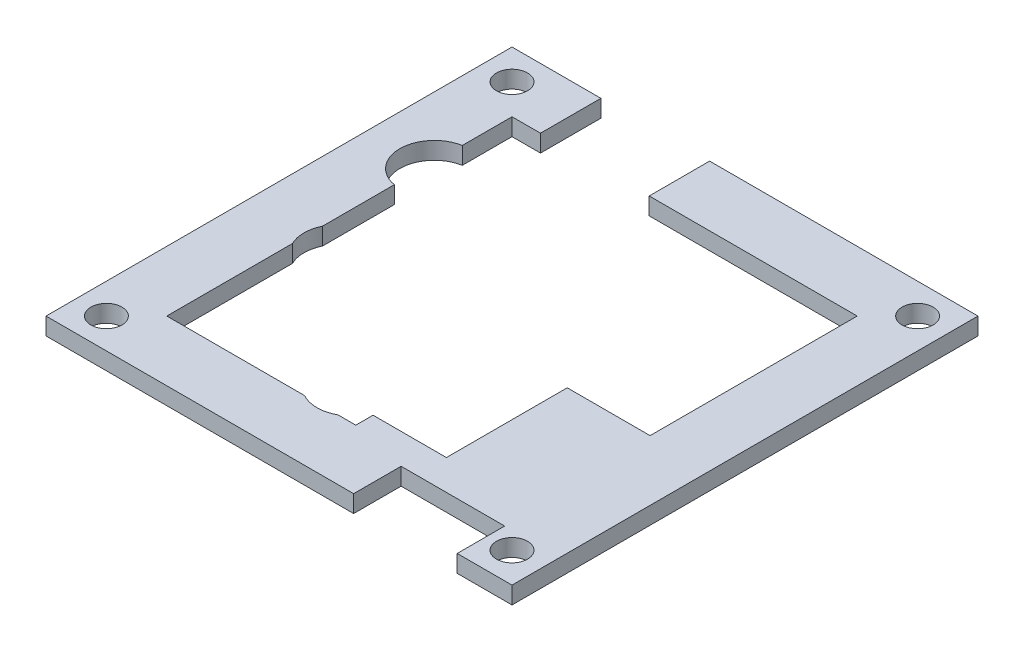
from build123d import *

# Parameters (mm, degrees)
SKETCH_3_R      = 1.8
SKETCH_3_W      = 0.8
SKETCH_3_H      = 1.5
SKETCH_3_W_2    = 1
EXTRUDE_2_DEPTH = 2


with BuildPart() as part:
    # 草图3 → 凸台-拉伸2 (new body)
    with BuildSketch(Plane(origin=(0, 0, 0), x_dir=(1, 0, 0), z_dir=(0, 1, 0))):
        with BuildLine():
            Line((8.65, -27), (8.65, -21.5))
            Line((8.65, -21.5), (8.65, -20))
            Line((8.65, -20), (1.9, -20))
            Line((1.9, -20), (-0.163508327, -20))
            ThreePointArc((-0.163508327, -20), (-2.1, -20.5), (-4.036491673, -20))
            Line((-4.036491673, -20), (-20, -20))
            Line((-20, -20), (-20, -5.443559577))
            ThreePointArc((-20, -5.443559577), (-20.4, -3.7), (-20, -1.956440423))
            Line((-20, -1.956440423), (-20, 6.361726266))
            ThreePointArc((-20, 6.361726266), (-23.3, 10.3), (-20, 14.238273734))
            Line((-20, 14.238273734), (-20, 20))
            Line((-20, 20), (-16.7, 20))
            Line((-16.7, 20), (-16.7, 27))
            Line((-16.7, 27), (-27, 27))
            Line((-27, 27), (-27, -27))
            Line((-27, -27), (8.65, -27))
        make_face()
        with Locations((-23.5, -23.5)):
            Circle(SKETCH_3_R, mode=Mode.SUBTRACT)
        with Locations((-23.5, 23.5)):
            Circle(SKETCH_3_R, mode=Mode.SUBTRACT)
        Polygon((20, -18), (20, -20), (20.65, -20), (20.65, -21.5), (20.65, -27), (27, -27), (27, 27), (-4.1, 27), (-4.1, 20), (20, 20), (20, -4), align=None)
        with Locations((23.5, -23.5)):
            Circle(SKETCH_3_R, mode=Mode.SUBTRACT)
        with Locations((23.5, 23.5)):
            Circle(SKETCH_3_R, mode=Mode.SUBTRACT)
        Polygon((12.4, -20), (12.4, -19.5), (12.4, -18), (10.4, -18), (1.9, -18), (1.9, -20), (8.65, -20), align=None)
        Polygon((20, -20), (16.9, -20), (16.9, -19.5), (16.1, -19.5), (13.4, -19.5), (12.4, -19.5), (12.4, -20), (8.65, -20), (8.65, -21.5), (20.65, -21.5), (20.65, -20), align=None)
        Polygon((16.9, -19.5), (16.9, -20), (20, -20), (20, -18), (16.9, -18), align=None)
        with Locations((16.5, -18.75)):
            Rectangle(SKETCH_3_W, SKETCH_3_H)
        with Locations((12.9, -18.75)):
            Rectangle(SKETCH_3_W_2, SKETCH_3_H)
        Polygon((16.1, -18), (16.9, -18), (16.9, -6), (12.4, -6), (12.4, -18), (13.4, -18), (13.4, -19.5), (16.1, -19.5), align=None)
        Polygon((16.9, -18), (20, -18), (20, -4), (10.4, -4), (10.4, -6), (10.4, -18), (12.4, -18), (12.4, -6), (16.9, -6), align=None)
    extrude(amount=EXTRUDE_2_DEPTH)


solid = part.part
